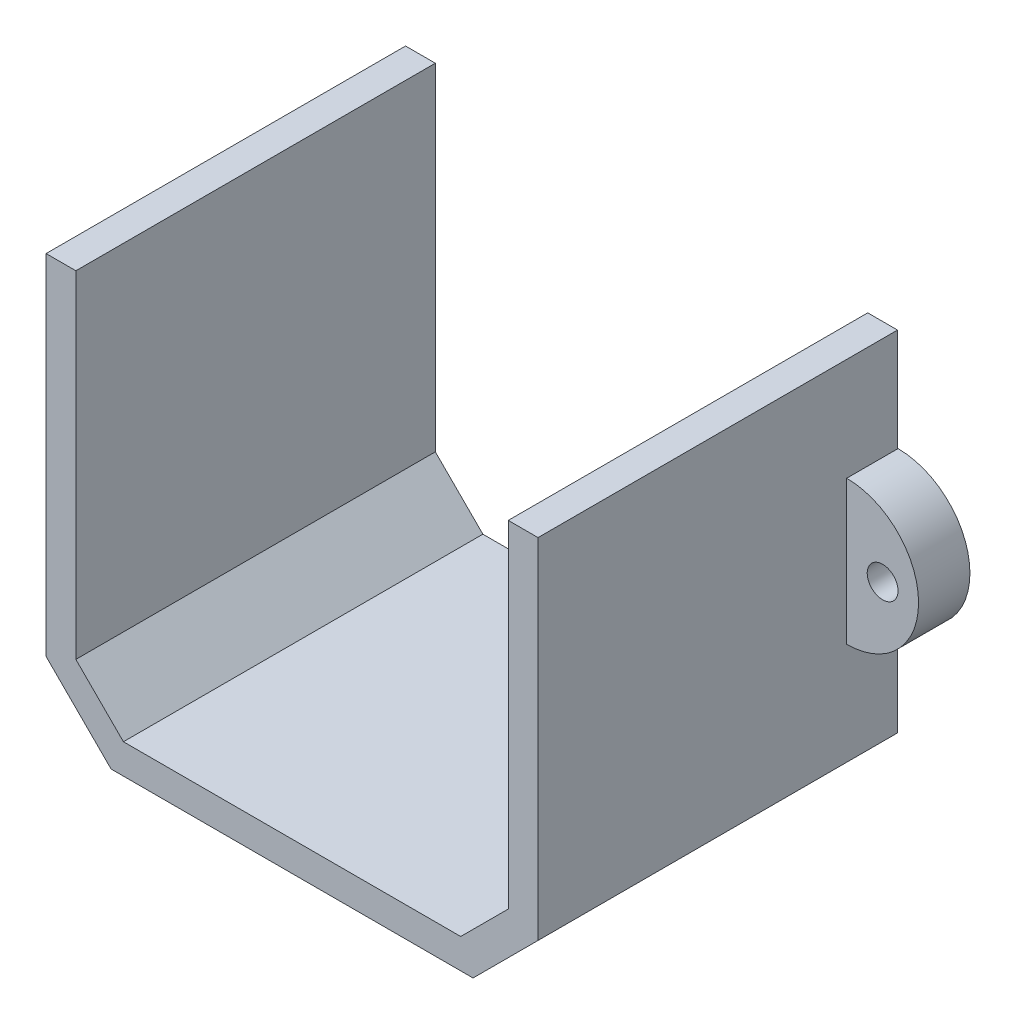
from build123d import *

# Parameters (mm, degrees)
BOSS_EXTRUDE1_DEPTH   = 35
SKETCH2_R             = 1.5
BOSS_EXTRUDE2_DEPTH   = 5
BOSS_EXTRUDE2_2_DEPTH = 5


with BuildPart() as part:
    # Sketch1 → Boss-Extrude1 (new body)
    with BuildSketch(Plane.XY):
        Polygon((21.10827062, 144.239197751), (21.10827062, 177.00990843), (24.00827062, 177.00990843), (24.00827062, 143.037978421), (17.68020063, 136.70990843), (-17.563659389, 136.70990843), (-23.89172938, 143.037978421), (-23.89172938, 177.00990843), (-20.99172938, 177.00990843), (-20.99172938, 144.239197751), (-16.362440058, 139.60990843), (16.478981299, 139.60990843), align=None)
    extrude(amount=BOSS_EXTRUDE1_DEPTH)


with BuildPart() as body_2:
    # Sketch2 → Boss-Extrude2 (new body)
    with BuildSketch(Plane.XY):
        with BuildLine():
            ThreePointArc((24.05827062, 167.038588086), (31.05827062, 160.038588086), (24.05827062, 153.038588086))
            Line((24.05827062, 153.038588086), (24.05827062, 167.038588086))
        make_face()
        with Locations((27.55827062, 160.038588086)):
            Circle(SKETCH2_R, mode=Mode.SUBTRACT)
    extrude(amount=BOSS_EXTRUDE2_DEPTH)


with BuildPart() as body_3:
    # Sketch2 → Boss-Extrude2 2 (new body)
    with BuildSketch(Plane.XY):
        with BuildLine():
            Line((-23.94172938, 167.038588086), (-23.94172938, 153.038588086))
            ThreePointArc((-23.94172938, 153.038588086), (-30.94172938, 160.038588086), (-23.94172938, 167.038588086))
        make_face()
        with Locations((-27.44172938, 160.038588086)):
            Circle(SKETCH2_R, mode=Mode.SUBTRACT)
    extrude(amount=BOSS_EXTRUDE2_2_DEPTH)


solid = Compound([part.part, body_2.part, body_3.part])
